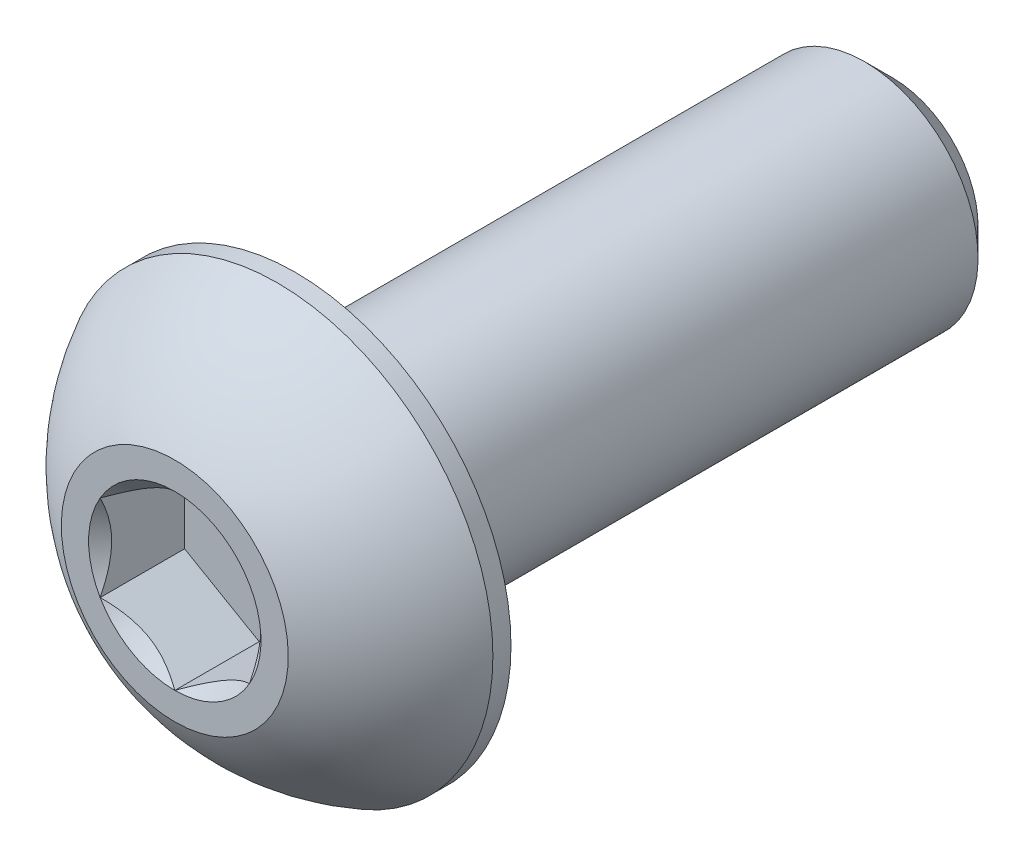
from build123d import *

# Parameters (mm, degrees)
SKETCH1_W          = 12.7
SKETCH1_H          = 2.413
CHAMFER1_SIZE      = 0.5953125
CUT_EXTRUDE2_DEPTH = 1.79578
SKETCH6_R          = 1.833087105
CUT_EXTRUDE3_DEPTH = 1.79578
CUT_EXTRUDE3_TAPER = 45


with BuildPart() as part:
    # Sketch1 → Revolve1 (revolve)
    with BuildSketch(Plane(origin=(0, 0, 0), x_dir=(0, 0, -1), z_dir=(1, 0, 0))):
        with Locations((8.9154, 1.2065)):
            Rectangle(SKETCH1_W, SKETCH1_H)
    revolve(axis=Axis((0, 0, -15.2654), (0, 0, 1)))

    # Chamfer1
    chamfer1_edges = [part.edges().sort_by_distance(p)[0] for p in [
        (0, -2.413, -15.2654),
    ]]
    chamfer(chamfer1_edges, length=CHAMFER1_SIZE)

    # Sketch7 → Revolve2 (revolve)
    with BuildSketch(Plane(origin=(0, 0, 0), x_dir=(0, 0, -1), z_dir=(1, 0, 0))):
        with BuildLine():
            Line((2.18059, 4.5847), (2.5654, 4.5847))
            Line((2.5654, 4.5847), (2.5654, 0))
            Line((2.5654, 0), (0, 0))
            Line((0, 0), (0, 2.413))
            ThreePointArc((0, 2.413), (0.925030326, 3.664791196), (2.18059, 4.5847))
        make_face()
    revolve(axis=Axis((0, 0, 0), (0, 0, -1)))

    # Sketch5 → Cut-Extrude2 (cut)
    with BuildSketch(Plane.XY):
        Polygon((1.5875, -0.916543552), (1.5875, 0.916543552), (0, 1.833087105), (-1.5875, 0.916543552), (-1.5875, -0.916543552), (0, -1.833087105), align=None)
    extrude(amount=-CUT_EXTRUDE2_DEPTH, mode=Mode.SUBTRACT)

    # Sketch6 → Cut-Extrude3 (cut)
    with BuildSketch(Plane.XY):
        Circle(SKETCH6_R)
    extrude(amount=-CUT_EXTRUDE3_DEPTH, taper=CUT_EXTRUDE3_TAPER, mode=Mode.SUBTRACT)


solid = part.part
